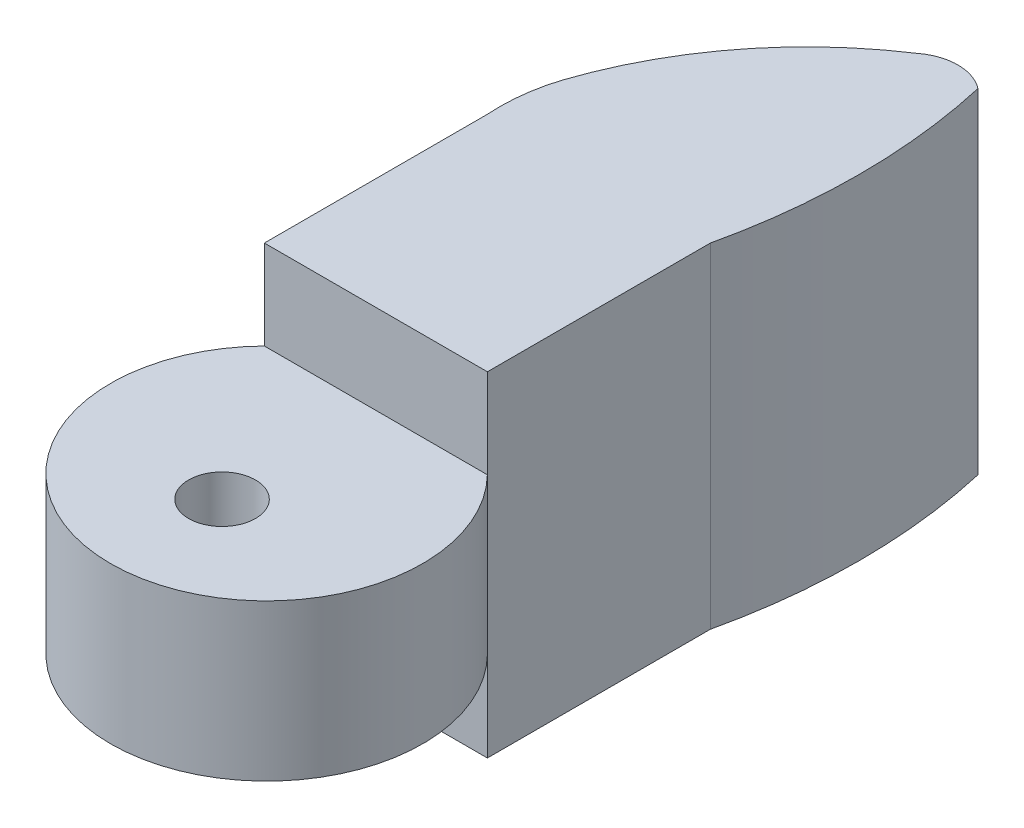
from build123d import *

# Parameters (mm, degrees)
SKETCH1_W                = 12.7
SKETCH1_H                = 19.05
BOSS_EXTRUDE1_DEPTH      = 12.7
BOSS_EXTRUDE3_DEPTH      = 4.445
BOSS_EXTRUDE3_DEPTH_BACK = 14.605
BOSS_EXTRUDE5_DEPTH      = 4.445
SKETCH9_R                = 1.905
CUT_EXTRUDE1_DEPTH       = 8.89


with BuildPart() as part:
    # Sketch1 → Boss-Extrude1 (new body)
    with BuildSketch(Plane.XY):
        Rectangle(SKETCH1_W, SKETCH1_H)
    extrude(amount=BOSS_EXTRUDE1_DEPTH)

    # Sketch5 → Boss-Extrude3 (add, two sides)
    with BuildSketch(Plane(origin=(0, 5.08, 0), x_dir=(1, 0, 0), z_dir=(0, 1, 0))) as boss_extrude3_sk:
        with BuildLine():
            Line((-6.35, 0), (6.35, 0))
            ThreePointArc((6.35, 0), (7.206801568, 7.62), (6.35, 15.24))
            ThreePointArc((6.35, 15.24), (4.615153625, 15.830989255), (2.88030725, 15.24))
            ThreePointArc((2.88030725, 15.24), (-2.482813439, 10.254375056), (-5.912749562, 3.784826555))
            ThreePointArc((-5.912749562, 3.784826555), (-6.305841352, 1.912568913), (-6.35, 0))
        make_face()
    extrude(amount=BOSS_EXTRUDE3_DEPTH)
    extrude(boss_extrude3_sk.sketch, amount=-BOSS_EXTRUDE3_DEPTH_BACK)

    # Sketch8 → Boss-Extrude5 (add, symmetric)
    with BuildSketch(Plane(origin=(0, 0, 0), x_dir=(1, 0, 0), z_dir=(0, 1, 0))):
        with BuildLine():
            Line((-6.35, -12.7), (6.35, -12.7))
            ThreePointArc((6.35, -12.7), (0, -27.811703947), (-6.35, -12.7))
        make_face()
    extrude(amount=BOSS_EXTRUDE5_DEPTH, both=True)

    # Sketch9 → Cut-Extrude1 (cut)
    with BuildSketch(Plane(origin=(0, 4.445, 0), x_dir=(1, 0, 0), z_dir=(0, 1, 0))):
        with Locations(Location((0, -21.461703947, 0), (0, 0, 270))):  # turned: the seam where the file's is
            Circle(SKETCH9_R)
    extrude(amount=-CUT_EXTRUDE1_DEPTH, mode=Mode.SUBTRACT)


solid = part.part
